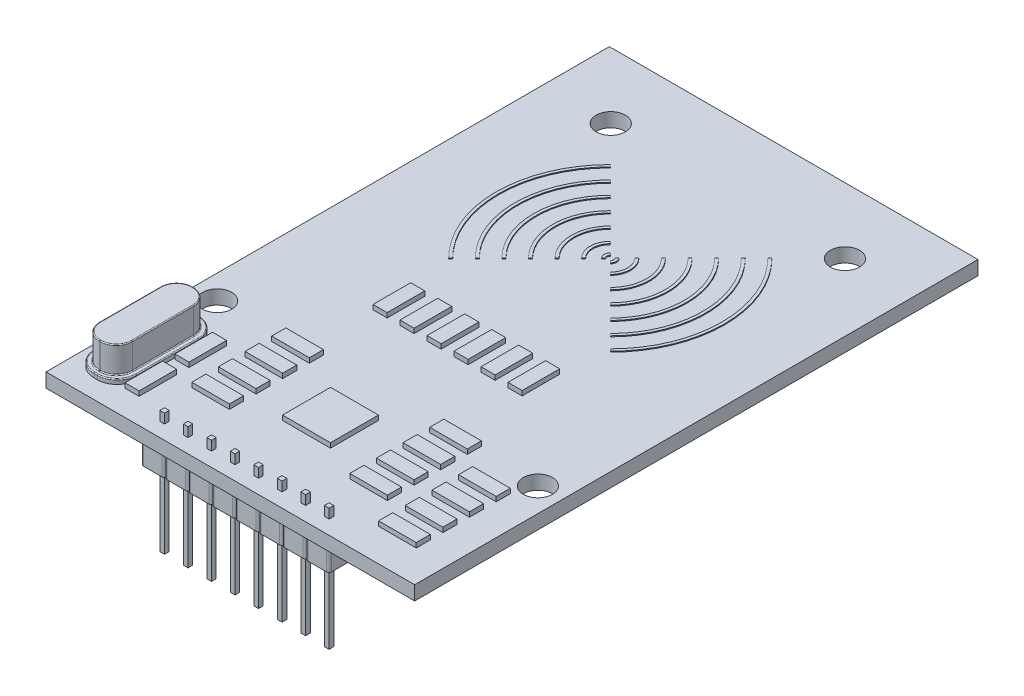
from build123d import *

# Parameters (mm, degrees)
SKETCH1_W                = 39.2
SKETCH1_H                = 59.9
BOSS_EXTRUDE1_DEPTH      = 1.5
SKETCH3_R                = 1.55
CUT_EXTRUDE1_DEPTH       = 1.5
BOSS_EXTRUDE3_DEPTH      = 4
BOSS_EXTRUDE4_DEPTH      = 0.5
BOSS_EXTRUDE5_DEPTH      = 2.8
FILLET1_R                = 0.1
BOSS_EXTRUDE6_DEPTH      = 0.1
ESBO_O1_W                = 1.5
ESBO_O1_H                = 4
ESBO_O1_W_2              = 4
ESBO_O1_H_2              = 1.5
RESSALTO_EXTRUS_O1_DEPTH = 0.5
ESBO_O2_W                = 5.1
ESBO_O2_H                = 5.1
RESSALTO_EXTRUS_O2_DEPTH = 0.5
SKETCH12_W               = 0.5
SKETCH12_H               = 0.5
CUT_EXTRUDE2_DEPTH       = 10
CUT_EXTRUDE2_DEPTH_BACK  = 10
SKETCH13_W               = 0.5
SKETCH13_H               = 0.5
BOSS_EXTRUDE8_DEPTH      = 8
BOSS_EXTRUDE8_DEPTH_BACK = 5


with BuildPart() as part:
    # Sketch1 → Boss-Extrude1 (new body)
    with BuildSketch(Plane(origin=(0, 0, 0), x_dir=(1, 0, 0), z_dir=(0, 1, 0))):
        Rectangle(SKETCH1_W, SKETCH1_H)
    extrude(amount=BOSS_EXTRUDE1_DEPTH)

    # Sketch3 → Cut-Extrude1 (cut)
    with BuildSketch(Plane(origin=(0, 1.5, 0), x_dir=(1, 0, 0), z_dir=(0, 1, 0))):
        with Locations((12.45, 22.95)):
            Circle(SKETCH3_R)
        with Locations((-12.45, 22.95)):
            Circle(SKETCH3_R)
        with Locations((17.05, -14.3)):
            Circle(SKETCH3_R)
        with Locations((-17.05, -14.3)):
            Circle(SKETCH3_R)
    extrude(amount=-CUT_EXTRUDE1_DEPTH, mode=Mode.SUBTRACT)

    # Sketch4 → Boss-Extrude3 (add)
    with BuildSketch(Plane(origin=(0, 1.5, 0), x_dir=(1, 0, 0), z_dir=(0, 1, 0))):
        with BuildLine():
            Line((-9.75, -26.95), (-7.75, -26.95))
            ThreePointArc((-7.75, -26.95), (-7.573223305, -27.023223305), (-7.5, -27.2))
            ThreePointArc((-7.5, -27.2), (-7.426776695, -27.023223305), (-7.25, -26.95))
            Line((-7.25, -26.95), (-5.25, -26.95))
            ThreePointArc((-5.25, -26.95), (-5.073223305, -27.023223305), (-5, -27.2))
            ThreePointArc((-5, -27.2), (-4.926776695, -27.023223305), (-4.75, -26.95))
            Line((-4.75, -26.95), (-2.75, -26.95))
            ThreePointArc((-2.75, -26.95), (-2.573223305, -27.023223305), (-2.5, -27.2))
            ThreePointArc((-2.5, -27.2), (-2.426776695, -27.023223305), (-2.25, -26.95))
            Line((-2.25, -26.95), (-0.25, -26.95))
            ThreePointArc((-0.25, -26.95), (-0.073223305, -27.023223305), (0, -27.2))
            ThreePointArc((0, -27.2), (0.073223305, -27.023223305), (0.25, -26.95))
            Line((0.25, -26.95), (2.25, -26.95))
            ThreePointArc((2.25, -26.95), (2.426776695, -27.023223305), (2.5, -27.2))
            ThreePointArc((2.5, -27.2), (2.573223305, -27.023223305), (2.75, -26.95))
            Line((2.75, -26.95), (4.75, -26.95))
            ThreePointArc((4.75, -26.95), (4.926776695, -27.023223305), (5, -27.2))
            ThreePointArc((5, -27.2), (5.073223305, -27.023223305), (5.25, -26.95))
            Line((5.25, -26.95), (7.25, -26.95))
            ThreePointArc((7.25, -26.95), (7.426776695, -27.023223305), (7.5, -27.2))
            ThreePointArc((7.5, -27.2), (7.573223305, -27.023223305), (7.75, -26.95))
            Line((7.75, -26.95), (9.75, -26.95))
            ThreePointArc((9.75, -26.95), (9.926776695, -27.023223305), (10, -27.2))
            Line((10, -27.2), (10, -29.2))
            ThreePointArc((10, -29.2), (9.926776695, -29.376776695), (9.75, -29.45))
            Line((9.75, -29.45), (7.75, -29.45))
            ThreePointArc((7.75, -29.45), (7.573223305, -29.376776695), (7.5, -29.2))
            ThreePointArc((7.5, -29.2), (7.426776695, -29.376776695), (7.25, -29.45))
            Line((7.25, -29.45), (5.25, -29.45))
            ThreePointArc((5.25, -29.45), (5.073223305, -29.376776695), (5, -29.2))
            ThreePointArc((5, -29.2), (4.926776695, -29.376776695), (4.75, -29.45))
            Line((4.75, -29.45), (2.75, -29.45))
            ThreePointArc((2.75, -29.45), (2.573223305, -29.376776695), (2.5, -29.2))
            ThreePointArc((2.5, -29.2), (2.426776695, -29.376776695), (2.25, -29.45))
            Line((2.25, -29.45), (0.25, -29.45))
            ThreePointArc((0.25, -29.45), (0.073223305, -29.376776695), (0, -29.2))
            ThreePointArc((0, -29.2), (-0.073223305, -29.376776695), (-0.25, -29.45))
            Line((-0.25, -29.45), (-2.25, -29.45))
            ThreePointArc((-2.25, -29.45), (-2.426776695, -29.376776695), (-2.5, -29.2))
            ThreePointArc((-2.5, -29.2), (-2.573223305, -29.376776695), (-2.75, -29.45))
            Line((-2.75, -29.45), (-4.75, -29.45))
            ThreePointArc((-4.75, -29.45), (-4.926776695, -29.376776695), (-5, -29.2))
            ThreePointArc((-5, -29.2), (-5.073223305, -29.376776695), (-5.25, -29.45))
            Line((-5.25, -29.45), (-7.25, -29.45))
            ThreePointArc((-7.25, -29.45), (-7.426776695, -29.376776695), (-7.5, -29.2))
            ThreePointArc((-7.5, -29.2), (-7.573223305, -29.376776695), (-7.75, -29.45))
            Line((-7.75, -29.45), (-9.75, -29.45))
            ThreePointArc((-9.75, -29.45), (-9.926776695, -29.376776695), (-10, -29.2))
            Line((-10, -29.2), (-10, -27.2))
            ThreePointArc((-10, -27.2), (-9.926776695, -27.023223305), (-9.75, -26.95))
        make_face()
    extrude(amount=-BOSS_EXTRUDE3_DEPTH)

    # Sketch8 → Boss-Extrude4 (add)
    with BuildSketch(Plane(origin=(0, 1.5, 0), x_dir=(1, 0, 0), z_dir=(0, 1, 0))):
        with BuildLine():
            Line((-16.5, -17.15), (-16.15, -17.15))
            ThreePointArc((-16.15, -17.15), (-14.66507576, -17.76507576), (-14.05, -19.25))
            Line((-14.05, -19.25), (-14.05, -25.85))
            ThreePointArc((-14.05, -25.85), (-14.66507576, -27.33492424), (-16.15, -27.95))
            Line((-16.15, -27.95), (-16.5, -27.95))
            ThreePointArc((-16.5, -27.95), (-17.98492424, -27.33492424), (-18.6, -25.85))
            Line((-18.6, -25.85), (-18.6, -19.25))
            ThreePointArc((-18.6, -19.25), (-17.98492424, -17.76507576), (-16.5, -17.15))
        make_face()
    extrude(amount=BOSS_EXTRUDE4_DEPTH)

    # Sketch10 → Boss-Extrude5 (add)
    with BuildSketch(Plane(origin=(0, 2, 0), x_dir=(1, 0, 0), z_dir=(0, 1, 0))):
        with BuildLine():
            Line((-16.375, -17.6), (-16.275, -17.6))
            ThreePointArc((-16.275, -17.6), (-15.072918472, -18.097918472), (-14.575, -19.3))
            Line((-14.575, -19.3), (-14.575, -25.8))
            ThreePointArc((-14.575, -25.8), (-15.072918472, -27.002081528), (-16.275, -27.5))
            Line((-16.275, -27.5), (-16.375, -27.5))
            ThreePointArc((-16.375, -27.5), (-17.577081528, -27.002081528), (-18.075, -25.8))
            Line((-18.075, -25.8), (-18.075, -19.3))
            ThreePointArc((-18.075, -19.3), (-17.577081528, -18.097918472), (-16.375, -17.6))
        make_face()
    extrude(amount=BOSS_EXTRUDE5_DEPTH)

    # Fillet1
    fillet1_edges = [part.edges().sort_by_distance(p)[0] for p in [
        (-17.98492424, 2, 27.33492424),
        (-16.325, 2, 27.95),
        (-14.66507576, 2, 27.33492424),
        (-14.05, 2, 22.55),
        (-14.66507576, 2, 17.76507576),
        (-16.325, 2, 17.15),
        (-17.98492424, 2, 17.76507576),
        (-18.6, 2, 22.55),
        (-17.577081528, 2, 27.002081528),
        (-16.325, 2, 27.5),
        (-15.072918472, 2, 27.002081528),
        (-14.575, 2, 22.55),
        (-15.072918472, 2, 18.097918472),
        (-16.325, 2, 17.6),
        (-17.577081528, 2, 18.097918472),
        (-18.075, 2, 22.55),
        (-17.577081528, 4.8, 27.002081528),
        (-16.325, 4.8, 27.5),
        (-15.072918472, 4.8, 27.002081528),
        (-14.575, 4.8, 22.55),
        (-15.072918472, 4.8, 18.097918472),
        (-16.325, 4.8, 17.6),
        (-17.577081528, 4.8, 18.097918472),
        (-18.075, 4.8, 22.55),
    ]]
    fillet(fillet1_edges, radius=FILLET1_R)

    # Sketch11 → Boss-Extrude6 (add)
    with BuildSketch(Plane(origin=(0, 1.5, 0), x_dir=(1, 0, 0), z_dir=(0, 1, 0))):
        with BuildLine():
            Line((-0.247487373, 10.697487373), (-0.459619408, 10.909619408))
            ThreePointArc((-0.459619408, 10.909619408), (-0.65, 10.45), (-0.459619408, 9.990380592))
            Line((-0.459619408, 9.990380592), (-0.247487373, 10.202512627))
            ThreePointArc((-0.247487373, 10.202512627), (-0.35, 10.45), (-0.247487373, 10.697487373))
        make_face()
        with BuildLine():
            Line((0.247487373, 10.697487373), (0.459619408, 10.909619408))
            ThreePointArc((0.459619408, 10.909619408), (0.65, 10.45), (0.459619408, 9.990380592))
            Line((0.459619408, 9.990380592), (0.247487373, 10.202512627))
            ThreePointArc((0.247487373, 10.202512627), (0.35, 10.45), (0.247487373, 10.697487373))
        make_face()
        with BuildLine():
            Line((-8.485281374, 18.935281374), (-8.591347391, 19.041347391))
            ThreePointArc((-8.591347391, 19.041347391), (-12.15, 10.45), (-8.591347391, 1.858652609))
            Line((-8.591347391, 1.858652609), (-8.485281374, 1.964718626))
            Line((-8.485281374, 1.964718626), (-8.379215357, 2.070784643))
            ThreePointArc((-8.379215357, 2.070784643), (-11.85, 10.45), (-8.379215357, 18.829215357))
            Line((-8.379215357, 18.829215357), (-8.485281374, 18.935281374))
        make_face()
        with BuildLine():
            Line((8.485281374, 1.964718626), (8.591347391, 1.858652609))
            ThreePointArc((8.591347391, 1.858652609), (12.15, 10.45), (8.591347391, 19.041347391))
            Line((8.591347391, 19.041347391), (8.485281374, 18.935281374))
            Line((8.485281374, 18.935281374), (8.379215357, 18.829215357))
            ThreePointArc((8.379215357, 18.829215357), (11.85, 10.45), (8.379215357, 2.070784643))
            Line((8.379215357, 2.070784643), (8.485281374, 1.964718626))
        make_face()
        with BuildLine():
            Line((-6.965001795, 17.415001795), (-7.177133829, 17.627133829))
            ThreePointArc((-7.177133829, 17.627133829), (-10.15, 10.45), (-7.177133829, 3.272866171))
            Line((-7.177133829, 3.272866171), (-6.965001795, 3.484998205))
            ThreePointArc((-6.965001795, 3.484998205), (-9.85, 10.45), (-6.965001795, 17.415001795))
        make_face()
        with BuildLine():
            Line((-5.550788232, 16.000788232), (-5.762920267, 16.212920267))
            ThreePointArc((-5.762920267, 16.212920267), (-8.15, 10.45), (-5.762920267, 4.687079733))
            Line((-5.762920267, 4.687079733), (-5.550788232, 4.899211768))
            ThreePointArc((-5.550788232, 4.899211768), (-7.85, 10.45), (-5.550788232, 16.000788232))
        make_face()
        with BuildLine():
            Line((-4.13657467, 14.58657467), (-4.348706704, 14.798706704))
            ThreePointArc((-4.348706704, 14.798706704), (-6.15, 10.45), (-4.348706704, 6.101293296))
            Line((-4.348706704, 6.101293296), (-4.13657467, 6.31342533))
            ThreePointArc((-4.13657467, 6.31342533), (-5.85, 10.45), (-4.13657467, 14.58657467))
        make_face()
        with BuildLine():
            Line((-2.722361108, 13.172361108), (-2.934493142, 13.384493142))
            ThreePointArc((-2.934493142, 13.384493142), (-4.15, 10.45), (-2.934493142, 7.515506858))
            Line((-2.934493142, 7.515506858), (-2.722361108, 7.727638892))
            ThreePointArc((-2.722361108, 7.727638892), (-3.85, 10.45), (-2.722361108, 13.172361108))
        make_face()
        with BuildLine():
            Line((-1.308147545, 11.758147545), (-1.52027958, 11.97027958))
            ThreePointArc((-1.52027958, 11.97027958), (-2.15, 10.45), (-1.52027958, 8.92972042))
            Line((-1.52027958, 8.92972042), (-1.308147545, 9.141852455))
            ThreePointArc((-1.308147545, 9.141852455), (-1.85, 10.45), (-1.308147545, 11.758147545))
        make_face()
        with BuildLine():
            Line((1.308147545, 9.141852455), (1.52027958, 8.92972042))
            ThreePointArc((1.52027958, 8.92972042), (2.15, 10.45), (1.52027958, 11.97027958))
            Line((1.52027958, 11.97027958), (1.308147545, 11.758147545))
            ThreePointArc((1.308147545, 11.758147545), (1.85, 10.45), (1.308147545, 9.141852455))
        make_face()
        with BuildLine():
            Line((2.722361108, 7.727638892), (2.934493142, 7.515506858))
            ThreePointArc((2.934493142, 7.515506858), (4.15, 10.45), (2.934493142, 13.384493142))
            Line((2.934493142, 13.384493142), (2.722361108, 13.172361108))
            ThreePointArc((2.722361108, 13.172361108), (3.85, 10.45), (2.722361108, 7.727638892))
        make_face()
        with BuildLine():
            Line((4.13657467, 6.31342533), (4.348706704, 6.101293296))
            ThreePointArc((4.348706704, 6.101293296), (6.15, 10.45), (4.348706704, 14.798706704))
            Line((4.348706704, 14.798706704), (4.13657467, 14.58657467))
            ThreePointArc((4.13657467, 14.58657467), (5.85, 10.45), (4.13657467, 6.31342533))
        make_face()
        with BuildLine():
            Line((5.550788232, 4.899211768), (5.762920267, 4.687079733))
            ThreePointArc((5.762920267, 4.687079733), (8.15, 10.45), (5.762920267, 16.212920267))
            Line((5.762920267, 16.212920267), (5.550788232, 16.000788232))
            ThreePointArc((5.550788232, 16.000788232), (7.85, 10.45), (5.550788232, 4.899211768))
        make_face()
        with BuildLine():
            Line((6.965001795, 3.484998205), (7.177133829, 3.272866171))
            ThreePointArc((7.177133829, 3.272866171), (10.15, 10.45), (7.177133829, 17.627133829))
            Line((7.177133829, 17.627133829), (6.965001795, 17.415001795))
            ThreePointArc((6.965001795, 17.415001795), (9.85, 10.45), (6.965001795, 3.484998205))
        make_face()
    extrude(amount=BOSS_EXTRUDE6_DEPTH)

    # Esbo_o1 → Ressalto-extrus_o1 (add)
    with BuildSketch(Plane(origin=(0, 1.5, 0), x_dir=(1, 0, 0), z_dir=(0, 1, 0))):
        with Locations((7.175, -4.85)):
            Rectangle(ESBO_O1_W, ESBO_O1_H)
        with Locations((4.305, -4.85)):
            Rectangle(ESBO_O1_W, ESBO_O1_H)
        with Locations((1.435, -4.85)):
            Rectangle(ESBO_O1_W, ESBO_O1_H)
        with Locations((-1.435, -4.85)):
            Rectangle(ESBO_O1_W, ESBO_O1_H)
        with Locations((-4.305, -4.85)):
            Rectangle(ESBO_O1_W, ESBO_O1_H)
        with Locations((-7.175, -4.85)):
            Rectangle(ESBO_O1_W, ESBO_O1_H)
        with Locations((-8.4, -22.9)):
            Rectangle(ESBO_O1_W_2, ESBO_O1_H_2)
        with Locations((-8.4, -20.066666667)):
            Rectangle(ESBO_O1_W_2, ESBO_O1_H_2)
        with Locations((-8.4, -17.233333333)):
            Rectangle(ESBO_O1_W_2, ESBO_O1_H_2)
        with Locations((-8.4, -14.4)):
            Rectangle(ESBO_O1_W_2, ESBO_O1_H_2)
        with Locations((8.4, -14.4)):
            Rectangle(ESBO_O1_W_2, ESBO_O1_H_2)
        with Locations((8.4, -17.233333333)):
            Rectangle(ESBO_O1_W_2, ESBO_O1_H_2)
        with Locations((8.4, -20.066666667)):
            Rectangle(ESBO_O1_W_2, ESBO_O1_H_2)
        with Locations((8.4, -22.9)):
            Rectangle(ESBO_O1_W_2, ESBO_O1_H_2)
        with Locations((-13.15, -19.95)):
            Rectangle(ESBO_O1_W, ESBO_O1_H)
        with Locations((-13.15, -25.25)):
            Rectangle(ESBO_O1_W, ESBO_O1_H)
        with Locations((14.3, -17.233333333)):
            Rectangle(ESBO_O1_W_2, ESBO_O1_H_2)
        with Locations((14.3, -20.066666667)):
            Rectangle(ESBO_O1_W_2, ESBO_O1_H_2)
        with Locations((14.3, -22.9)):
            Rectangle(ESBO_O1_W_2, ESBO_O1_H_2)
        with Locations((14.3, -25.733333333)):
            Rectangle(ESBO_O1_W_2, ESBO_O1_H_2)
    extrude(amount=RESSALTO_EXTRUS_O1_DEPTH)

    # Esbo_o2 → Ressalto-extrus_o2 (add)
    with BuildSketch(Plane(origin=(0, 1.5, 0), x_dir=(1, 0, 0), z_dir=(0, 1, 0))):
        with Locations((0, -19.3)):
            Rectangle(ESBO_O2_W, ESBO_O2_H)
    extrude(amount=RESSALTO_EXTRUS_O2_DEPTH)

    # Sketch12 → Cut-Extrude2 (cut, two sides)
    with BuildSketch(Plane.XZ.offset(2.5)) as cut_extrude2_sk:
        with Locations((6.25, 28.2)):
            Rectangle(SKETCH12_W, SKETCH12_H)
        with Locations((8.75, 28.2)):
            Rectangle(SKETCH12_W, SKETCH12_H)
        with Locations((3.75, 28.2)):
            Rectangle(SKETCH12_W, SKETCH12_H)
        with Locations((1.25, 28.2)):
            Rectangle(SKETCH12_W, SKETCH12_H)
        with Locations((-1.25, 28.2)):
            Rectangle(SKETCH12_W, SKETCH12_H)
        with Locations((-3.75, 28.2)):
            Rectangle(SKETCH12_W, SKETCH12_H)
        with Locations((-6.25, 28.2)):
            Rectangle(SKETCH12_W, SKETCH12_H)
        with Locations((-8.75, 28.2)):
            Rectangle(SKETCH12_W, SKETCH12_H)
    extrude(amount=CUT_EXTRUDE2_DEPTH, mode=Mode.SUBTRACT)
    extrude(cut_extrude2_sk.sketch, amount=-CUT_EXTRUDE2_DEPTH_BACK, mode=Mode.SUBTRACT)

    # Sketch13 → Boss-Extrude8 (add, two sides)
    with BuildSketch(Plane.XZ.offset(2.5)) as boss_extrude8_sk:
        with Locations((6.25, 28.2)):
            Rectangle(SKETCH13_W, SKETCH13_H)
        with Locations((8.75, 28.2)):
            Rectangle(SKETCH13_W, SKETCH13_H)
        with Locations((-8.75, 28.2)):
            Rectangle(SKETCH13_W, SKETCH13_H)
        with Locations((-6.25, 28.2)):
            Rectangle(SKETCH13_W, SKETCH13_H)
        with Locations((-3.75, 28.2)):
            Rectangle(SKETCH13_W, SKETCH13_H)
        with Locations((1.25, 28.2)):
            Rectangle(SKETCH13_W, SKETCH13_H)
        with Locations((-1.25, 28.2)):
            Rectangle(SKETCH13_W, SKETCH13_H)
        with Locations((3.75, 28.2)):
            Rectangle(SKETCH13_W, SKETCH13_H)
    extrude(amount=BOSS_EXTRUDE8_DEPTH)
    extrude(boss_extrude8_sk.sketch, amount=-BOSS_EXTRUDE8_DEPTH_BACK)


solid = part.part
